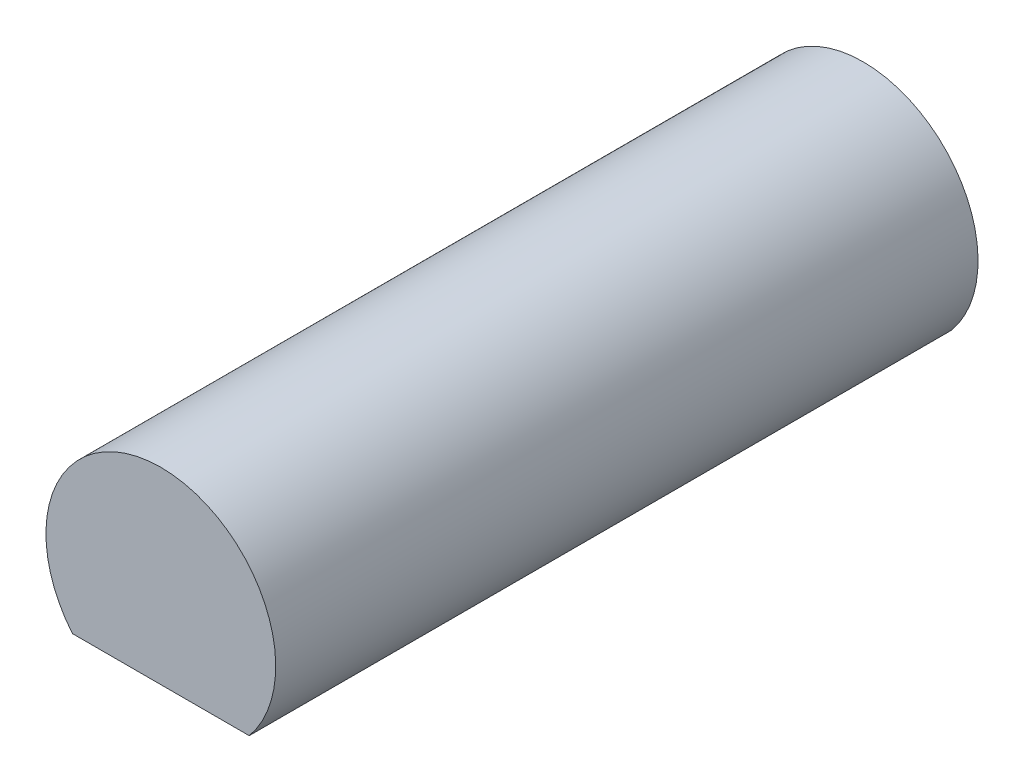
from build123d import *

# Parameters (mm, degrees)
BOSS_EXTRU_1_DEPTH = 9.14


with BuildPart() as part:
    # Esquisse1 → Boss.-Extru.1 (new body)
    with BuildSketch(Plane.XY):
        with BuildLine():
            Line((0, -0.955), (1.150217371, -0.955))
            ThreePointArc((1.150217371, -0.955), (0, 1.495), (-1.150217371, -0.955))
            Line((-1.150217371, -0.955), (0, -0.955))
        make_face()
    extrude(amount=BOSS_EXTRU_1_DEPTH)


solid = part.part
